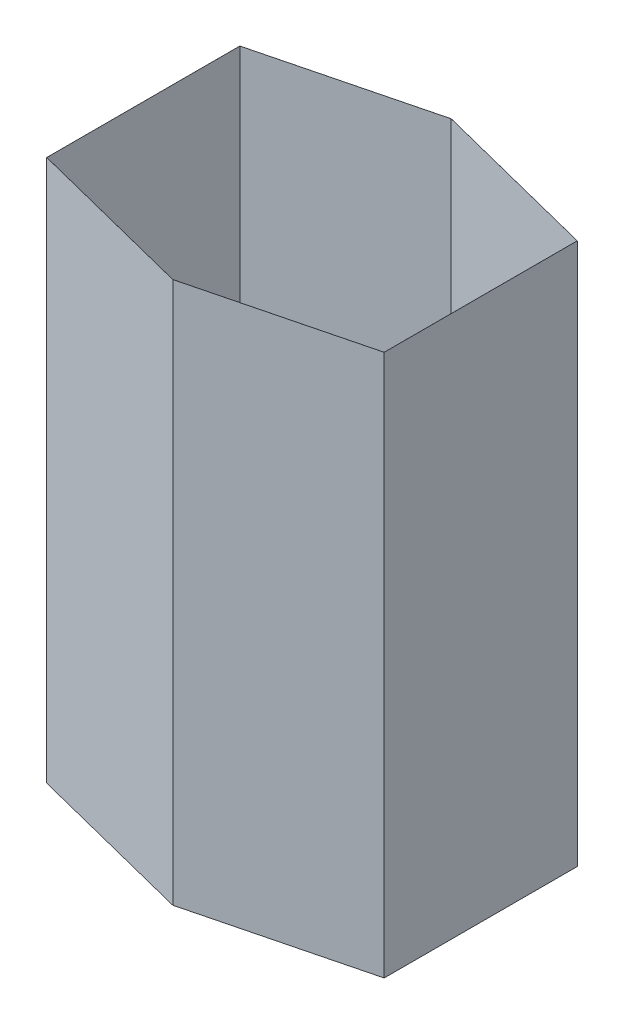
from build123d import *

# Parameters (mm, degrees)
EXTRU_MINCE1_DEPTH = 350


with BuildPart() as part:
    # Esquisse2 → Extru.-Mince1 (new body)
    with BuildSketch(Plane(origin=(0, 0, 0), x_dir=(1, 0, 0), z_dir=(0, 1, 0))):
        Polygon((128.154934328, 62.357784789), (128.154934328, -62.357784789), (19.179270891, -89.932841208), (-89.796392545, -62.357784789), (-89.796392545, 62.357784789), (19.179270891, 89.932841208), align=None)
        Polygon((128.144934328, 62.35), (128.144934328, -62.35), (19.179270891, -89.922526032), (-89.786392545, -62.35), (-89.786392545, 62.35), (19.179270891, 89.922526032), align=None, mode=Mode.SUBTRACT)
    extrude(amount=EXTRU_MINCE1_DEPTH)


solid = part.part
